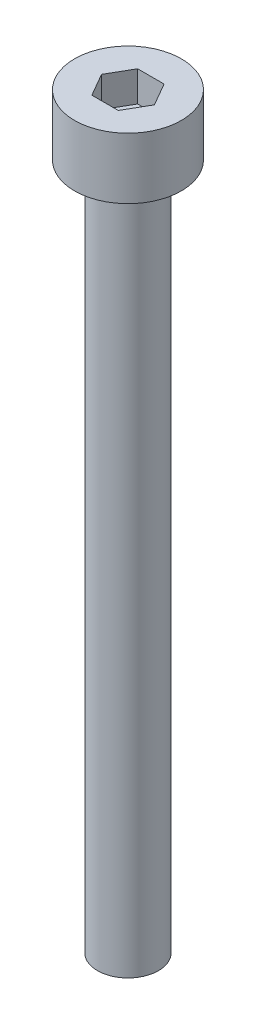
from build123d import *

# Parameters (mm, degrees)
SKETCH_1_R            = 3.5
EXTRUDE_246_DEPTH     = 4
CUT_EXTRUDE_376_DEPTH = 2
SKETCH_3_R            = 2
EXTRUDE_477_DEPTH     = 45


with BuildPart() as part:
    # 草图1 → Extrude 246 (new body)
    with BuildSketch(Plane(origin=(0, 0, 0), x_dir=(1, 0, 0), z_dir=(0, 1, 0))):
        Circle(SKETCH_1_R)
    extrude(amount=EXTRUDE_246_DEPTH)

    # 草图2 → Cut-Extrude 376 (cut)
    with BuildSketch(Plane(origin=(0, 4, 0), x_dir=(1, 0, 0), z_dir=(0, 1, 0))):
        Polygon((1.732050808, 0), (0.866025404, 1.5), (-0.866025404, 1.5), (-1.732050808, 0), (-0.866025404, -1.5), (0.866025404, -1.5), align=None)
    extrude(amount=-CUT_EXTRUDE_376_DEPTH, mode=Mode.SUBTRACT)

    # 草图3 → Extrude 477 (add)
    with BuildSketch(Plane.XZ):
        Circle(SKETCH_3_R)
    extrude(amount=EXTRUDE_477_DEPTH)


solid = part.part
